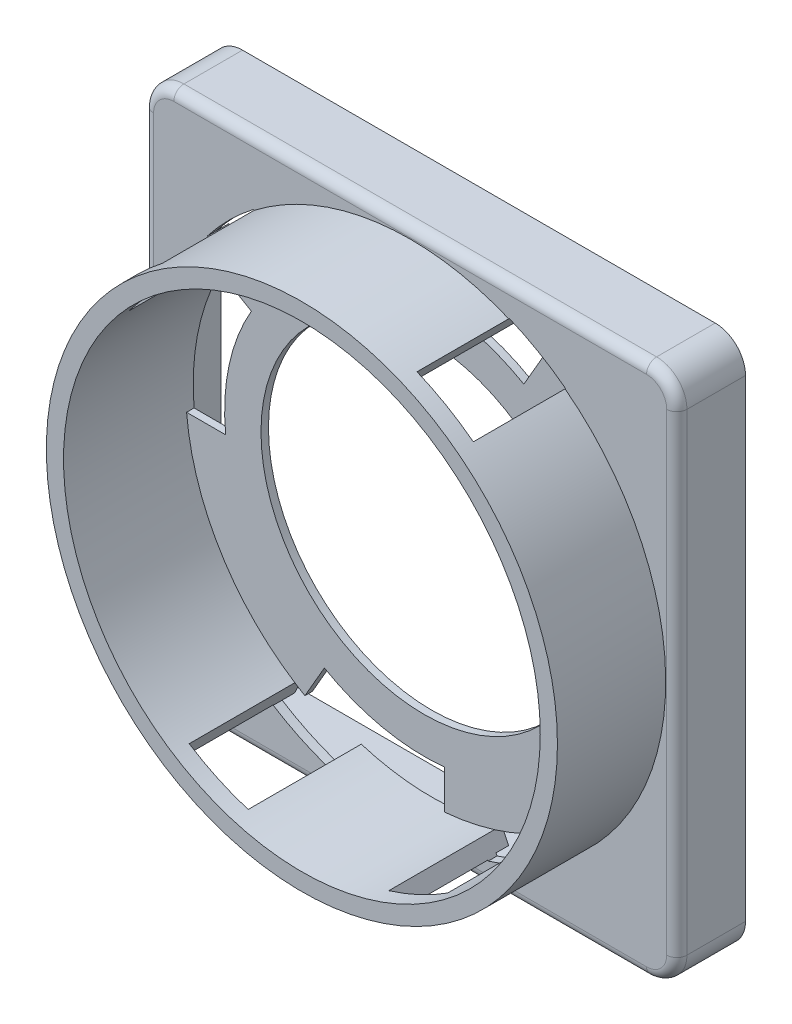
from build123d import *

# Parameters (mm, degrees)
BASE_EXTRUDE_DEPTH  = 8.636
SHELL1_T            = -1.1176
SKETCH2_R           = 32.131
BOSS_EXTRUDE1_DEPTH = 13.6144
SKETCH3_R           = 32.2326
BOSS_EXTRUDE2_DEPTH = 1.5748
CUT_EXTRUDE2_START  = -1.5748
CUT_EXTRUDE2_DEPTH  = 1.5748
SKETCH5_R           = 29.972
CUT_EXTRUDE3_DEPTH  = 15.367
SKETCH6_R           = 20.5105
CUT_EXTRUDE4_DEPTH  = 7.8834
CUT_EXTRUDE5_DEPTH  = 7.8834
CIRPATTERN1_COUNT   = 4
CUT_EXTRUDE6_DEPTH  = 14.224
CUT_EXTRUDE7_DEPTH  = 14.224
CUT_EXTRUDE8_DEPTH  = 14.224
CIRPATTERN2_COUNT   = 2
CIRPATTERN2_ANGLE   = 310
FILLET1_R           = 1.27


with BuildPart() as part:
    # Sketch1 → Base-Extrude (new body)
    with BuildSketch(Plane.XY):
        with BuildLine():
            Line((3.81, 0), (63.246, 0))
            ThreePointArc((63.246, 0), (65.940076836, 1.115923164), (67.056, 3.81))
            Line((67.056, 3.81), (67.056, 63.246))
            ThreePointArc((67.056, 63.246), (65.940076836, 65.940076836), (63.246, 67.056))
            Line((63.246, 67.056), (3.81, 67.056))
            ThreePointArc((3.81, 67.056), (1.115923164, 65.940076836), (0, 63.246))
            Line((0, 63.246), (0, 3.81))
            ThreePointArc((0, 3.81), (1.115923164, 1.115923164), (3.81, 0))
        make_face()
    extrude(amount=-BASE_EXTRUDE_DEPTH)

    # Shell1
    shell1_openings = [part.faces().sort_by_distance(p)[0] for p in [
        (33.528, 33.528, -8.636),
    ]]
    offset(amount=SHELL1_T, openings=shell1_openings, kind=Kind.INTERSECTION)

    # Sketch2 → Boss-Extrude1 (add)
    with BuildSketch(Plane.XY):
        with Locations((33.528, 33.528)):
            Circle(SKETCH2_R)
    extrude(amount=BOSS_EXTRUDE1_DEPTH)

    # Sketch3 → Boss-Extrude2 (add)
    with BuildSketch(Plane(origin=(0, 0, -1.1176), x_dir=(-1, 0, 0), z_dir=(0, 0, -1))):
        with Locations((-33.528, 33.528)):
            Circle(SKETCH3_R)
    extrude(amount=BOSS_EXTRUDE2_DEPTH)

    # Sketch4 → Cut-Extrude2 (cut)
    with BuildSketch(Plane(origin=(0, 0, -2.6924), x_dir=(-1, 0, 0), z_dir=(0, 0, -1)).offset(CUT_EXTRUDE2_START)):
        with BuildLine():
            Line((-63.246, 65.9384), (-3.81, 65.9384))
            ThreePointArc((-3.81, 65.9384), (-1.906185702, 65.149814298), (-1.1176, 63.246))
            Line((-1.1176, 63.246), (-1.1176, 3.81))
            ThreePointArc((-1.1176, 3.81), (-1.906185702, 1.906185702), (-3.81, 1.1176))
            Line((-3.81, 1.1176), (-63.246, 1.1176))
            ThreePointArc((-63.246, 1.1176), (-65.149814298, 1.906185702), (-65.9384, 3.81))
            Line((-65.9384, 3.81), (-65.9384, 63.246))
            ThreePointArc((-65.9384, 63.246), (-65.149814298, 65.149814298), (-63.246, 65.9384))
        make_face()
        with BuildLine():
            Line((-3.81, 63.9572), (-63.246, 63.9572))
            ThreePointArc((-63.246, 63.9572), (-63.748894343, 63.748894343), (-63.9572, 63.246))
            Line((-63.9572, 63.246), (-63.9572, 3.81))
            ThreePointArc((-63.9572, 3.81), (-63.748894343, 3.307105657), (-63.246, 3.0988))
            Line((-63.246, 3.0988), (-3.81, 3.0988))
            ThreePointArc((-3.81, 3.0988), (-3.307105657, 3.307105657), (-3.0988, 3.81))
            Line((-3.0988, 3.81), (-3.0988, 63.246))
            ThreePointArc((-3.0988, 63.246), (-3.307105657, 63.748894343), (-3.81, 63.9572))
        make_face(mode=Mode.SUBTRACT)
    extrude(amount=CUT_EXTRUDE2_DEPTH, mode=Mode.SUBTRACT)

    # Sketch5 → Cut-Extrude3 (cut)
    with BuildSketch(Plane.XY.offset(13.6144)):
        with Locations((33.528, 33.528)):
            Circle(SKETCH5_R)
    extrude(amount=-CUT_EXTRUDE3_DEPTH, mode=Mode.SUBTRACT)

    # Sketch6 → Cut-Extrude4 (cut, through all)
    with BuildSketch(Plane.XY.offset(-1.7526)):
        with Locations((33.528, 33.528)):
            Circle(SKETCH6_R)
    extrude(amount=-CUT_EXTRUDE4_DEPTH, mode=Mode.SUBTRACT)

    # Sketch7 → Cut-Extrude5 (cut, through all)
    with BuildSketch(Plane.XY.offset(-1.7526)):
        with BuildLine():
            Line((30.988, 63.392178944), (30.988, 58.481560993))
            ThreePointArc((30.988, 58.481560993), (38.783174993, 58.053801558), (46.06925, 55.25008219))
            Line((46.06925, 55.25008219), (48.514, 59.484513402))
            ThreePointArc((48.514, 59.484513402), (40.050514201, 62.781676564), (30.988, 63.392178944))
        make_face()
    cut_extrude5 = extrude(amount=-CUT_EXTRUDE5_DEPTH, mode=Mode.SUBTRACT)

    # CirPattern1: Cut-Extrude5 ×4 about axis
    cirpattern1_axis = Axis((33.528, 33.528, 0), (0, 0, 1))
    for i in range(1, CIRPATTERN1_COUNT):
        add(cut_extrude5.rotate(cirpattern1_axis, i * 360 / CIRPATTERN1_COUNT), mode=Mode.SUBTRACT)

    # Sketch8 → Cut-Extrude6 (cut)
    with BuildSketch(Plane(origin=(0, 0, -2.6924), x_dir=(-1, 0, 0), z_dir=(0, 0, -1))):
        with BuildLine():
            Line((-45.972542384, 63.261379687), (-44.832330284, 61.286474397))
            ThreePointArc((-44.832330284, 61.286474397), (-48.514, 59.484513402), (-51.915378856, 57.197074397))
            Line((-51.915378856, 57.197074397), (-53.055590957, 59.171979687))
            ThreePointArc((-53.055590957, 59.171979687), (-49.6443, 61.44225043), (-45.972542384, 63.261379687))
        make_face()
    extrude(amount=-CUT_EXTRUDE6_DEPTH, mode=Mode.SUBTRACT)

    # Sketch9 → Cut-Extrude7 (cut)
    with BuildSketch(Plane(origin=(0, 0, -2.6924), x_dir=(-1, 0, 0), z_dir=(0, 0, -1))):
        with BuildLine():
            Line((-8.028645234, 53.244069824), (-9.641148651, 51.631566407))
            ThreePointArc((-9.641148651, 51.631566407), (-12.334595554, 54.721404446), (-15.424433593, 57.414851349))
            Line((-15.424433593, 57.414851349), (-13.811930176, 59.027354766))
            ThreePointArc((-13.811930176, 59.027354766), (-10.736109965, 56.319890035), (-8.028645234, 53.244069824))
        make_face()
    extrude(amount=-CUT_EXTRUDE7_DEPTH, mode=Mode.SUBTRACT)

    # Sketch10 → Cut-Extrude8 (cut)
    with BuildSketch(Plane(origin=(0, 0, -2.6924), x_dir=(-1, 0, 0), z_dir=(0, 0, -1))):
        with BuildLine():
            Line((-17.273486431, 8.346427916), (-16.309737519, 6.279661704))
            ThreePointArc((-16.309737519, 6.279661704), (-19.513159966, 4.501722912), (-22.897652399, 3.0988))
            Line((-22.897652399, 3.0988), (-23.85078467, 3.0988))
            Line((-23.85078467, 3.0988), (-24.68599656, 4.889917677))
            ThreePointArc((-24.68599656, 4.889917677), (-20.861285459, 6.364143007), (-17.273486431, 8.346427916))
        make_face()
    cut_extrude8 = extrude(amount=-CUT_EXTRUDE8_DEPTH, mode=Mode.SUBTRACT)

    # CirPattern2: Cut-Extrude8 ×2 about axis
    cirpattern2_axis = Axis((33.528, 33.528, 0), (0, 0, -1))
    for i in range(1, CIRPATTERN2_COUNT):
        add(cut_extrude8.rotate(cirpattern2_axis, i * CIRPATTERN2_ANGLE / (CIRPATTERN2_COUNT - 1)), mode=Mode.SUBTRACT)

    # Fillet1
    fillet1_edges = [part.edges().sort_by_distance(p)[0] for p in [
        (33.528, 0, 0),
        (1.115923164, 1.115923164, 0),
        (0, 33.528, 0),
        (1.115923164, 65.940076836, 0),
        (33.528, 67.056, 0),
        (65.940076836, 65.940076836, 0),
        (67.056, 33.528, 0),
        (65.940076836, 1.115923164, 0),
    ]]
    fillet(fillet1_edges, radius=FILLET1_R)


solid = part.part
